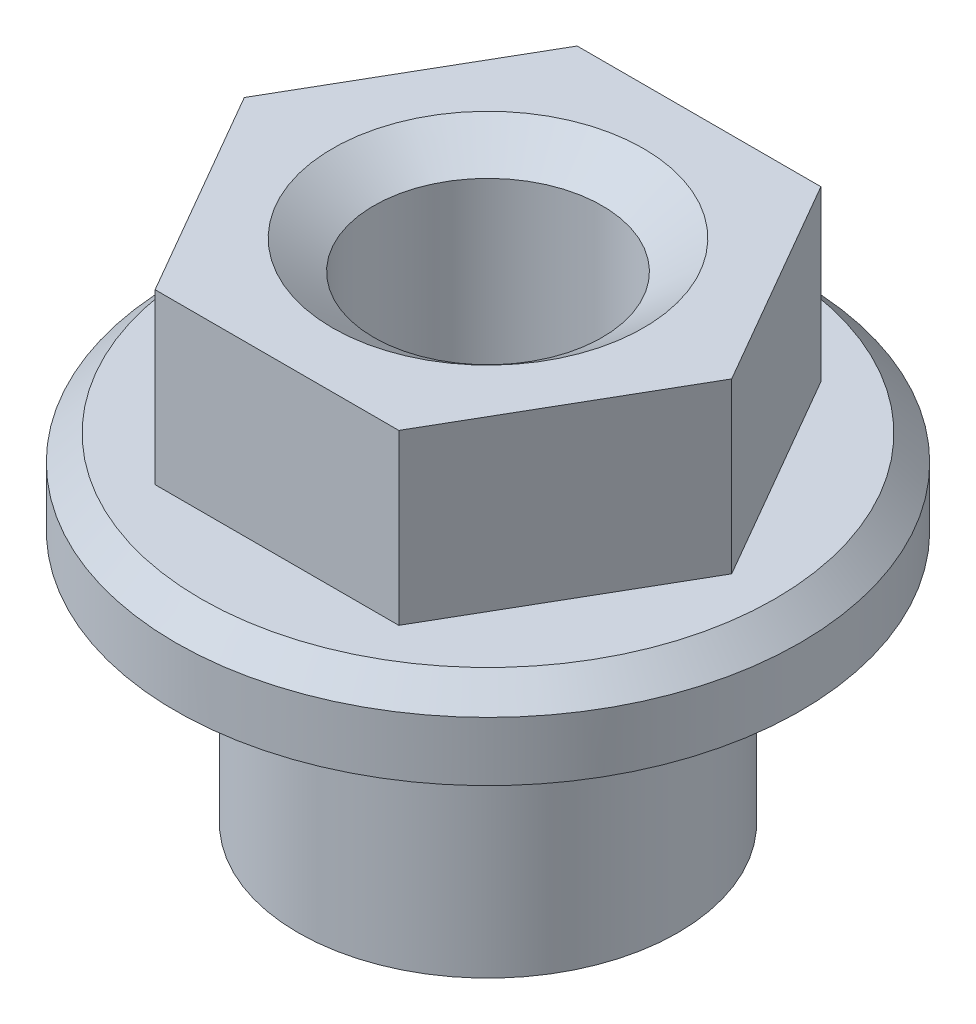
from build123d import *

# Parameters (mm, degrees)
SKETCH_7_OUTSIDE_W  = 11.812
SKETCH_7_OUTSIDE_H  = 11.812
CUT_EXTRUDE_1_DEPTH = 2
CHAMFER_1_SIZE      = 0.3


with BuildPart() as part:
    # Эскиз1 → Повернуть1 (revolve)
    with BuildSketch(Plane.XY):
        Polygon((0, 0), (-2.25, 0), (-2.25, 3), (-3.7, 3), (-3.7, 6), (0, 6), align=None)
    revolve(axis=Axis((0, 0, 0), (0, 1, 0)))

    # Эскиз3 → Отверстие обработанное метчиком #6-321 (revolve, cut)
    with BuildSketch(Plane(origin=(0, 6, 0), x_dir=(0, 0, 1), z_dir=(1, 0, 0))):
        Polygon((0, 0), (0, 6), (1.8415, 6), (1.35255, 5.657633524), (1.35255, 0.342366476), (1.8415, 0), align=None)
    revolve(axis=Axis((0, 12.35, 0), (0, -1, 0)), mode=Mode.SUBTRACT)

    # Эскиз7 outside → Вырез-Вытянуть1 (cut)
    with BuildSketch(Plane(origin=(0, 6, 0), x_dir=(1, 0, 0), z_dir=(0, 1, 0))):
        Rectangle(SKETCH_7_OUTSIDE_W, SKETCH_7_OUTSIDE_H)
        Polygon((2.886751346, 0), (1.443375673, 2.5), (-1.443375673, 2.5), (-2.886751346, 0), (-1.443375673, -2.5), (1.443375673, -2.5), align=None, mode=Mode.SUBTRACT)
    extrude(amount=-CUT_EXTRUDE_1_DEPTH, mode=Mode.SUBTRACT)

    # Фаска1
    chamfer_1_edges = [part.edges().sort_by_distance(p)[0] for p in [
        (3.7, 4, 0),
    ]]
    chamfer(chamfer_1_edges, length=CHAMFER_1_SIZE)


solid = part.part
